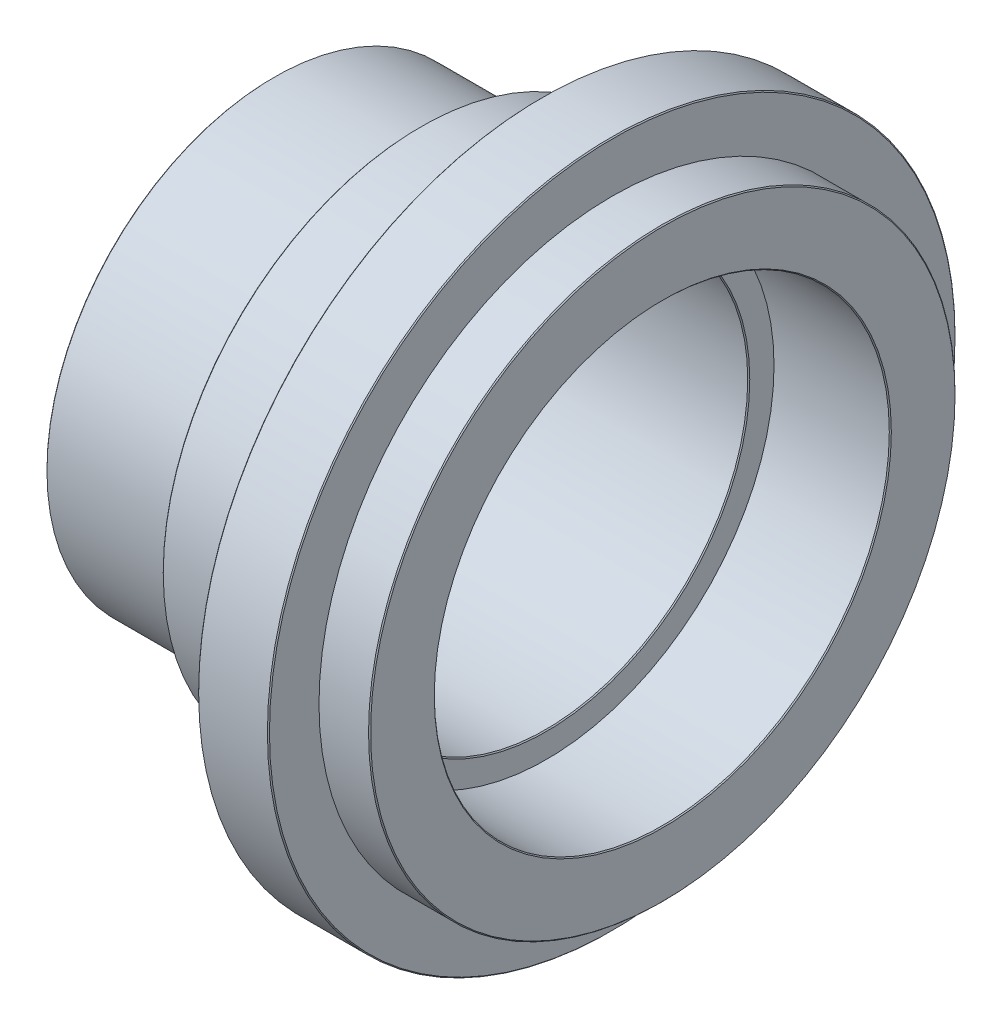
from build123d import *

# Parameters (mm, degrees)
CHANFREIN1_SIZE = 0.2
CHANFREIN2_SIZE = 0.2


with BuildPart() as part:
    # Esquisse1 → Révolution1 (revolve)
    with BuildSketch(Plane.XY, mode=Mode.PRIVATE) as r_volution1_sk:
        Polygon((0, 45), (0, 58), (-10, 58), (-10, 68), (-24, 68), (-24, 56.196152423), (-27, 51), (-48, 51), (-48, 45), (-77, 45), (-77, 40), (-23, 40), (-23, 45), align=None)
    revolve(r_volution1_sk.sketch.rotate(Axis((0, 0, 0), (-1, 0, 0)), 90), axis=Axis((0, 0, 0), (-1, 0, 0)))  # turned: the seam where the file's is

    # Chanfrein1
    chanfrein1_edges = [part.edges().sort_by_distance(p)[0] for p in [
        (-48, 0, 51),
        (-77, 0, 45),
        (-77, 0, 40),
        (0, 0, 45),
        (0, 0, 58),
        (-10, 0, 68),
        (-24, 0, 68),
    ]]
    chamfer(chanfrein1_edges, length=CHANFREIN1_SIZE)

    # Chanfrein2
    chanfrein2_edges = [part.edges().sort_by_distance(p)[0] for p in [
        (-23, 0, 40),
    ]]
    chamfer(chanfrein2_edges, length=CHANFREIN2_SIZE)


solid = part.part
